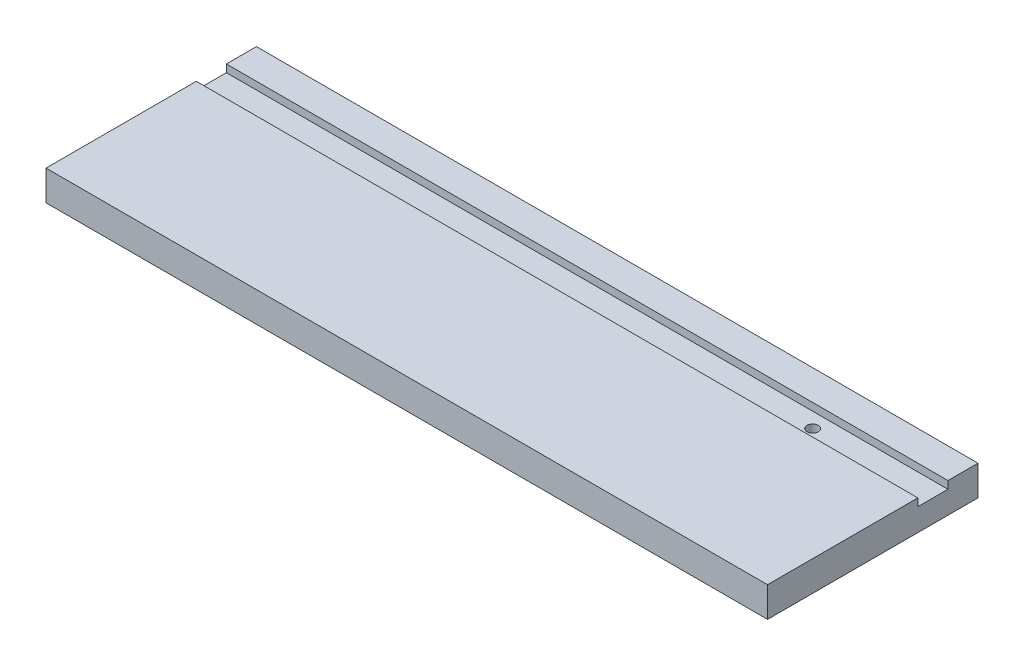
from build123d import *

# Parameters (mm, degrees)
SKETCH1_W           = 152.4
SKETCH1_H           = 44.45
BOSS_EXTRUDE2_DEPTH = 6.35
SKETCH2_W           = 146.05
SKETCH2_H           = 6.35
CUT_EXTRUDE1_DEPTH  = 1.6002
SKETCH3_R           = 1.18745
CUT_EXTRUDE2_DEPTH  = 5.7498
SKETCH4_W           = 6.35
SKETCH4_H           = 6.35
CUT_EXTRUDE4_DEPTH  = 1.6002


with BuildPart() as part:
    # Sketch1 → Boss-Extrude2 (new body)
    with BuildSketch(Plane(origin=(0, 0, 0), x_dir=(1, 0, 0), z_dir=(0, 1, 0))):
        with Locations((76.2, 22.225)):
            Rectangle(SKETCH1_W, SKETCH1_H)
    extrude(amount=BOSS_EXTRUDE2_DEPTH)

    # Sketch2 → Cut-Extrude1 (cut)
    with BuildSketch(Plane(origin=(0, 6.35, 0), x_dir=(1, 0, 0), z_dir=(0, 1, 0))):
        with Locations((79.375, 34.925)):
            Rectangle(SKETCH2_W, SKETCH2_H)
    extrude(amount=-CUT_EXTRUDE1_DEPTH, mode=Mode.SUBTRACT)

    # Sketch3 → Cut-Extrude2 (cut, through all)
    with BuildSketch(Plane(origin=(0, 4.7498, 0), x_dir=(1, 0, 0), z_dir=(0, 1, 0))):
        with Locations((127, 34.925)):
            Circle(SKETCH3_R)
    extrude(amount=-CUT_EXTRUDE2_DEPTH, mode=Mode.SUBTRACT)

    # Sketch4 → Cut-Extrude4 (cut)
    with BuildSketch(Plane(origin=(0, 6.35, 0), x_dir=(1, 0, 0), z_dir=(0, 1, 0))):
        with Locations((3.175, 34.925)):
            Rectangle(SKETCH4_W, SKETCH4_H)
    extrude(amount=-CUT_EXTRUDE4_DEPTH, mode=Mode.SUBTRACT)


solid = part.part
